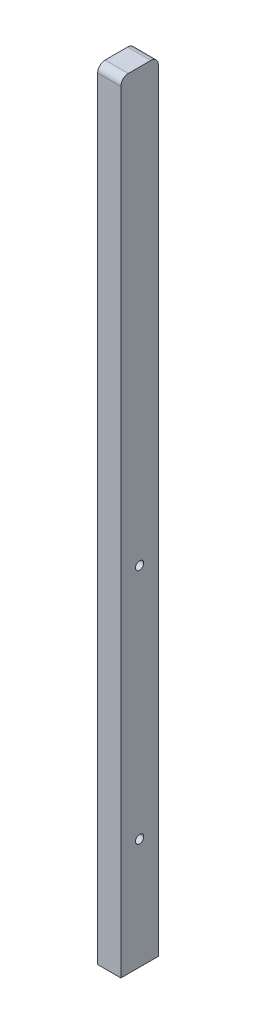
from build123d import *

# Parameters (mm, degrees)
SKETCH1_W                                           = 15.5
SKETCH1_H                                           = 25
BOSS_EXTRUDE1_DEPTH                                 = 520
FILLET1_R                                           = 5
F_5_0MM_DOWEL_HOLE1_D                               = 6.6
F_5_0MM_DOWEL_HOLE1_DEPTH                           = 12
F_5_0MM_DOWEL_HOLE1_TIP                             = 1.982840043
CBORE_FOR_M5_HEX_SOCKET_HEAD_CAP_SCREW2_D           = 5.5
CBORE_FOR_M5_HEX_SOCKET_HEAD_CAP_SCREW2_CBORE_D     = 10
CBORE_FOR_M5_HEX_SOCKET_HEAD_CAP_SCREW2_CBORE_DEPTH = 5.4


with BuildPart() as part:
    # Sketch1 → Boss-Extrude1 (new body)
    with BuildSketch(Plane(origin=(0, 0, 0), x_dir=(1, 0, 0), z_dir=(0, 1, 0))):
        Rectangle(SKETCH1_W, SKETCH1_H)
    extrude(amount=BOSS_EXTRUDE1_DEPTH)

    # Fillet1
    fillet1_edges = [part.edges().sort_by_distance(p)[0] for p in [
        (0, 520, -12.5),
        (0, 520, 12.5),
    ]]
    fillet(fillet1_edges, radius=FILLET1_R)

    # Ø5.0mm Dowel Hole1
    with Locations(Plane(origin=(0, 0, 0), x_dir=(-1, 0, 0), z_dir=(0, -1, 0))):
        with Locations((0, 0)):
            Hole(F_5_0MM_DOWEL_HOLE1_D / 2, depth=F_5_0MM_DOWEL_HOLE1_DEPTH)
            with Locations((0, 0, -(F_5_0MM_DOWEL_HOLE1_DEPTH + F_5_0MM_DOWEL_HOLE1_TIP / 2))):  # 118° drill point
                Cone(0, F_5_0MM_DOWEL_HOLE1_D / 2, F_5_0MM_DOWEL_HOLE1_TIP, mode=Mode.SUBTRACT)

    # CBORE for M5 Hex Socket Head Cap Screw2 (through all)
    with Locations(Plane.ZY.offset(7.75)):
        with Locations((0, 74), (0, 232)):
            CounterBoreHole(CBORE_FOR_M5_HEX_SOCKET_HEAD_CAP_SCREW2_D / 2, CBORE_FOR_M5_HEX_SOCKET_HEAD_CAP_SCREW2_CBORE_D / 2, CBORE_FOR_M5_HEX_SOCKET_HEAD_CAP_SCREW2_CBORE_DEPTH)


solid = part.part
